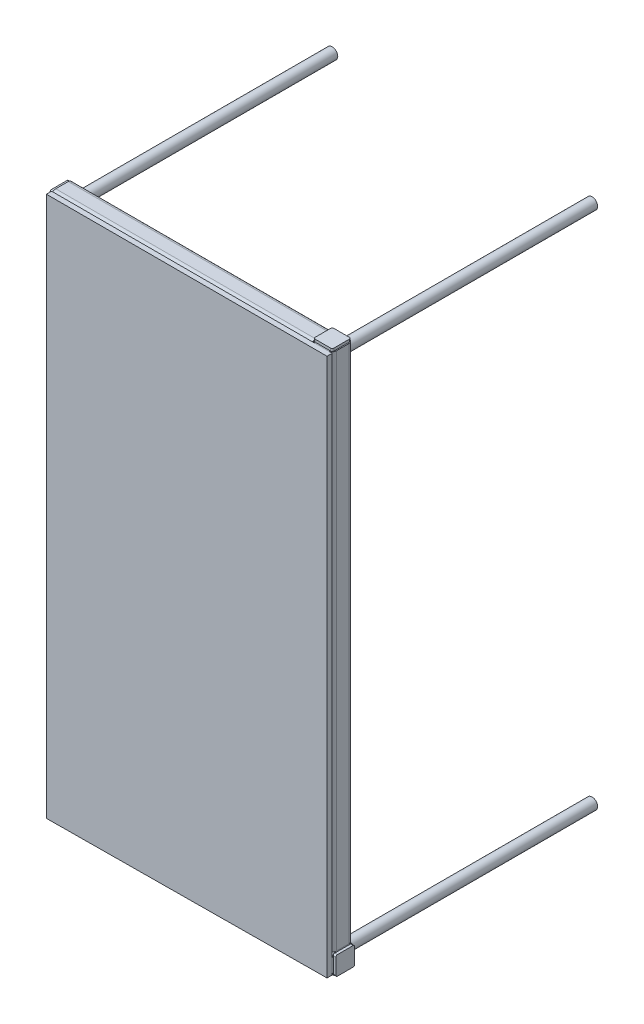
from build123d import *

# Parameters (mm, degrees)
STRUCTURAL_MEMBER1_DEPTH      = 1020
STRUCTURAL_MEMBER1_DEPTH_BACK = 1
STRUCTURAL_MEMBER1_2_DEPTH    = 521
STRUCTURAL_MEMBER1_3_DEPTH    = 1021
STRUCTURAL_MEMBER1_4_DEPTH    = 521
SKETCH11_R                    = 10.65
SKETCH11_R_2                  = 8.35
STRUCTURAL_MEMBER2_DEPTH      = 500
SKETCH11_ON_SEGMENT_2_R       = 10.65
SKETCH11_ON_SEGMENT_2_R_2     = 8.35
STRUCTURAL_MEMBER2_2_DEPTH    = 500
SKETCH11_ON_SEGMENT_3_R       = 10.65
SKETCH11_ON_SEGMENT_3_R_2     = 8.35
STRUCTURAL_MEMBER2_3_DEPTH    = 500
SKETCH11_ON_SEGMENT_4_R       = 10.65
SKETCH11_ON_SEGMENT_4_R_2     = 8.35
STRUCTURAL_MEMBER2_4_DEPTH    = 500
END_CAP1_WIDTH                = 36
END_CAP1_HEIGHT               = 36
END_CAP1_THICKNESS            = 5
END_CAP1_2_SIZE               = 3
GUSSET1_THICKNESS             = 5
BOSS_EXTRUDE1_DEPTH           = 10
END_CAP2_WIDTH                = 36
END_CAP2_HEIGHT               = 36
END_CAP2_THICKNESS            = 5
END_CAP2_2_R                  = 3
END_CAP3_WIDTH                = 36
END_CAP3_HEIGHT               = 36
END_CAP3_THICKNESS            = 5
END_CAP3_2_R                  = 3
END_CAP4_WIDTH                = 36
END_CAP4_HEIGHT               = 36
END_CAP4_THICKNESS            = 5
END_CAP4_2_R                  = 3


with BuildPart() as part:
    # Sketch1 → Structural Member1 (new, two sides)
    with BuildSketch(Plane(origin=(-250, 500, 0), x_dir=(1, 0, 0), z_dir=(0, -1, 0))) as structural_member1_sk:
        with BuildLine():
            Line((-12, -20), (12, -20))
            ThreePointArc((12, -20), (17.656854249, -17.656854249), (20, -12))
            Line((20, -12), (20, 12))
            ThreePointArc((20, 12), (17.656854249, 17.656854249), (12, 20))
            Line((12, 20), (-12, 20))
            ThreePointArc((-12, 20), (-17.656854249, 17.656854249), (-20, 12))
            Line((-20, 12), (-20, -12))
            ThreePointArc((-20, -12), (-17.656854249, -17.656854249), (-12, -20))
        make_face()
        with BuildLine():
            Line((-12, -16), (12, -16))
            ThreePointArc((12, -16), (14.828427125, -14.828427125), (16, -12))
            Line((16, -12), (16, 12))
            ThreePointArc((16, 12), (14.828427125, 14.828427125), (12, 16))
            Line((12, 16), (-12, 16))
            ThreePointArc((-12, 16), (-14.828427125, 14.828427125), (-16, 12))
            Line((-16, 12), (-16, -12))
            ThreePointArc((-16, -12), (-14.828427125, -14.828427125), (-12, -16))
        make_face(mode=Mode.SUBTRACT)
    extrude(amount=STRUCTURAL_MEMBER1_DEPTH)
    extrude(structural_member1_sk.sketch, amount=-STRUCTURAL_MEMBER1_DEPTH_BACK)

    # Structural Member1 end butt 1
    split(bisect_by=Plane(origin=(-250, 480, 0), x_dir=(1, 0, 0), z_dir=(0, -1, 0)), keep=Keep.TOP)


with BuildPart() as body_2:
    # Sketch1 on segment 2 (carried to segment 2) → Structural Member1 2 (new body)
    with BuildSketch(Plane(origin=(-251, -500, 0), x_dir=(0, 1, 0), z_dir=(1, 0, 0))):
        with BuildLine():
            Line((-12, -20), (12, -20))
            ThreePointArc((12, -20), (17.656854249, -17.656854249), (20, -12))
            Line((20, -12), (20, 12))
            ThreePointArc((20, 12), (17.656854249, 17.656854249), (12, 20))
            Line((12, 20), (-12, 20))
            ThreePointArc((-12, 20), (-17.656854249, 17.656854249), (-20, 12))
            Line((-20, 12), (-20, -12))
            ThreePointArc((-20, -12), (-17.656854249, -17.656854249), (-12, -20))
        make_face()
        with BuildLine():
            Line((-12, -16), (12, -16))
            ThreePointArc((12, -16), (14.828427125, -14.828427125), (16, -12))
            Line((16, -12), (16, 12))
            ThreePointArc((16, 12), (14.828427125, 14.828427125), (12, 16))
            Line((12, 16), (-12, 16))
            ThreePointArc((-12, 16), (-14.828427125, 14.828427125), (-16, 12))
            Line((-16, 12), (-16, -12))
            ThreePointArc((-16, -12), (-14.828427125, -14.828427125), (-12, -16))
        make_face(mode=Mode.SUBTRACT)
    extrude(amount=STRUCTURAL_MEMBER1_2_DEPTH)

    # Structural Member1 2 end butt 1
    split(bisect_by=Plane(origin=(-230, -500, 0), x_dir=(0, 1, 0), z_dir=(1, 0, 0)), keep=Keep.TOP)


with BuildPart() as body_3:
    # Sketch1 on segment 3 (carried to segment 3) → Structural Member1 3 (new body)
    with BuildSketch(Plane(origin=(250, -501, 0), x_dir=(-1, 0, 0), z_dir=(0, 1, 0))):
        with BuildLine():
            Line((-12, -20), (12, -20))
            ThreePointArc((12, -20), (17.656854249, -17.656854249), (20, -12))
            Line((20, -12), (20, 12))
            ThreePointArc((20, 12), (17.656854249, 17.656854249), (12, 20))
            Line((12, 20), (-12, 20))
            ThreePointArc((-12, 20), (-17.656854249, 17.656854249), (-20, 12))
            Line((-20, 12), (-20, -12))
            ThreePointArc((-20, -12), (-17.656854249, -17.656854249), (-12, -20))
        make_face()
        with BuildLine():
            Line((-12, -16), (12, -16))
            ThreePointArc((12, -16), (14.828427125, -14.828427125), (16, -12))
            Line((16, -12), (16, 12))
            ThreePointArc((16, 12), (14.828427125, 14.828427125), (12, 16))
            Line((12, 16), (-12, 16))
            ThreePointArc((-12, 16), (-14.828427125, 14.828427125), (-16, 12))
            Line((-16, 12), (-16, -12))
            ThreePointArc((-16, -12), (-14.828427125, -14.828427125), (-12, -16))
        make_face(mode=Mode.SUBTRACT)
    extrude(amount=STRUCTURAL_MEMBER1_3_DEPTH)

    # Structural Member1 3 end butt 1
    split(bisect_by=Plane(origin=(250, -480, 0), x_dir=(-1, 0, 0), z_dir=(0, 1, 0)), keep=Keep.TOP)


with BuildPart() as body_4:
    # Sketch1 on segment 4 (carried to segment 4) → Structural Member1 4 (new body)
    with BuildSketch(Plane(origin=(251, 500, 0), x_dir=(0, -1, 0), z_dir=(-1, 0, 0))):
        with BuildLine():
            Line((-12, -20), (12, -20))
            ThreePointArc((12, -20), (17.656854249, -17.656854249), (20, -12))
            Line((20, -12), (20, 12))
            ThreePointArc((20, 12), (17.656854249, 17.656854249), (12, 20))
            Line((12, 20), (-12, 20))
            ThreePointArc((-12, 20), (-17.656854249, 17.656854249), (-20, 12))
            Line((-20, 12), (-20, -12))
            ThreePointArc((-20, -12), (-17.656854249, -17.656854249), (-12, -20))
        make_face()
        with BuildLine():
            Line((-12, -16), (12, -16))
            ThreePointArc((12, -16), (14.828427125, -14.828427125), (16, -12))
            Line((16, -12), (16, 12))
            ThreePointArc((16, 12), (14.828427125, 14.828427125), (12, 16))
            Line((12, 16), (-12, 16))
            ThreePointArc((-12, 16), (-14.828427125, 14.828427125), (-16, 12))
            Line((-16, 12), (-16, -12))
            ThreePointArc((-16, -12), (-14.828427125, -14.828427125), (-12, -16))
        make_face(mode=Mode.SUBTRACT)
    extrude(amount=STRUCTURAL_MEMBER1_4_DEPTH)

    # Structural Member1 4 end butt 1
    split(bisect_by=Plane(origin=(230, 500, 0), x_dir=(0, -1, 0), z_dir=(-1, 0, 0)), keep=Keep.TOP)


with BuildPart() as body_5:
    # Sketch11 → Structural Member2 (new body)
    with BuildSketch(Plane(origin=(-250, -500, 0), x_dir=(1, 0, 0), z_dir=(0, 0, -1))):
        Circle(SKETCH11_R)
        Circle(SKETCH11_R_2, mode=Mode.SUBTRACT)
    extrude(amount=STRUCTURAL_MEMBER2_DEPTH)

    # Trim/Extend1
    split(bisect_by=Plane(origin=(20, -500, -20), x_dir=(0, 1, 0), z_dir=(0, 0, -1)), keep=Keep.TOP)


with BuildPart() as body_6:
    # Sketch11 on segment 2 (carried to segment 2) → Structural Member2 2 (new body)
    with BuildSketch(Plane(origin=(250, -500, 0), x_dir=(1, 0, 0), z_dir=(0, 0, -1))):
        Circle(SKETCH11_ON_SEGMENT_2_R)
        Circle(SKETCH11_ON_SEGMENT_2_R_2, mode=Mode.SUBTRACT)
    extrude(amount=STRUCTURAL_MEMBER2_2_DEPTH)

    # Trim/Extend1
    split(bisect_by=Plane(origin=(20, -500, -20), x_dir=(0, 1, 0), z_dir=(0, 0, -1)), keep=Keep.TOP)


with BuildPart() as body_7:
    # Sketch11 on segment 3 (carried to segment 3) → Structural Member2 3 (new body)
    with BuildSketch(Plane(origin=(-250, 500, 0), x_dir=(1, 0, 0), z_dir=(0, 0, -1))):
        Circle(SKETCH11_ON_SEGMENT_3_R)
        Circle(SKETCH11_ON_SEGMENT_3_R_2, mode=Mode.SUBTRACT)
    extrude(amount=STRUCTURAL_MEMBER2_3_DEPTH)

    # Trim/Extend1
    split(bisect_by=Plane(origin=(20, -500, -20), x_dir=(0, 1, 0), z_dir=(0, 0, -1)), keep=Keep.TOP)


with BuildPart() as body_8:
    # Sketch11 on segment 4 (carried to segment 4) → Structural Member2 4 (new body)
    with BuildSketch(Plane(origin=(250, 500, 0), x_dir=(1, 0, 0), z_dir=(0, 0, -1))):
        Circle(SKETCH11_ON_SEGMENT_4_R)
        Circle(SKETCH11_ON_SEGMENT_4_R_2, mode=Mode.SUBTRACT)
    extrude(amount=STRUCTURAL_MEMBER2_4_DEPTH)

    # Trim/Extend1
    split(bisect_by=Plane(origin=(20, -500, -20), x_dir=(0, 1, 0), z_dir=(0, 0, -1)), keep=Keep.TOP)


with BuildPart() as body_9:
    # End cap1: an end cap: a rectangular plate 5.0 thick over the member's open end
    with BuildSketch(Plane(origin=(-250, -520, 0), x_dir=(1, 0, 0), z_dir=(0, -1, 0))):
        Rectangle(END_CAP1_WIDTH, END_CAP1_HEIGHT)
    extrude(amount=END_CAP1_THICKNESS)

    # End cap1 2
    end_cap1_2_edges = [body_9.edges().sort_by_distance(p)[0] for p in [
        (-268, -522.5, -18),
        (-268, -522.5, 18),
        (-232, -522.5, -18),
        (-232, -522.5, 18),
    ]]
    chamfer(end_cap1_2_edges, length=END_CAP1_2_SIZE)


with BuildPart() as body_10:
    # Gusset1: a gusset: a plate 5.0 thick in the corner of two members, its outline drawn in place
    gusset1_outline = Wire([Line((-230, -480, -2.5), (-230, -455, -2.5)), Line((-230, -455, -2.5), (-205, -480, -2.5)), Line((-205, -480, -2.5), (-230, -480, -2.5))])
    add(extrude(Face(gusset1_outline), amount=GUSSET1_THICKNESS, dir=(0, 0, 1)))


with BuildPart() as body_11:
    # Sketch13 → Boss-Extrude1 (new body)
    with BuildSketch(Plane.XY.offset(20)):
        Polygon((-270, -520), (270, -516), (270, 520), (-270, 520), align=None)
    extrude(amount=BOSS_EXTRUDE1_DEPTH)


with BuildPart() as body_12:
    # End cap2: an end cap: a rectangular plate 5.0 thick over the member's open end
    with BuildSketch(Plane(origin=(270, -500, 0), x_dir=(0, 1, 0), z_dir=(1, 0, 0))):
        Rectangle(END_CAP2_WIDTH, END_CAP2_HEIGHT)
    extrude(amount=END_CAP2_THICKNESS)

    # End cap2 2
    end_cap2_2_edges = [body_12.edges().sort_by_distance(p)[0] for p in [
        (272.5, -518, -18),
        (272.5, -518, 18),
        (272.5, -482, -18),
        (272.5, -482, 18),
    ]]
    fillet(end_cap2_2_edges, radius=END_CAP2_2_R)


with BuildPart() as body_13:
    # End cap3: an end cap: a rectangular plate 5.0 thick over the member's open end
    with BuildSketch(Plane(origin=(250, 520, 0), x_dir=(-1, 0, 0), z_dir=(0, 1, 0))):
        Rectangle(END_CAP3_WIDTH, END_CAP3_HEIGHT)
    extrude(amount=END_CAP3_THICKNESS)

    # End cap3 2
    end_cap3_2_edges = [body_13.edges().sort_by_distance(p)[0] for p in [
        (268, 522.5, -18),
        (268, 522.5, 18),
        (232, 522.5, -18),
        (232, 522.5, 18),
    ]]
    fillet(end_cap3_2_edges, radius=END_CAP3_2_R)


with BuildPart() as body_14:
    # End cap4: an end cap: a rectangular plate 5.0 thick over the member's open end
    with BuildSketch(Plane(origin=(-270, 500, 0), x_dir=(0, -1, 0), z_dir=(-1, 0, 0))):
        Rectangle(END_CAP4_WIDTH, END_CAP4_HEIGHT)
    extrude(amount=END_CAP4_THICKNESS)

    # End cap4 2
    end_cap4_2_edges = [body_14.edges().sort_by_distance(p)[0] for p in [
        (-272.5, 518, -18),
        (-272.5, 518, 18),
        (-272.5, 482, -18),
        (-272.5, 482, 18),
    ]]
    fillet(end_cap4_2_edges, radius=END_CAP4_2_R)


solid = Compound([part.part, body_2.part, body_3.part, body_4.part, body_5.part, body_6.part, body_7.part, body_8.part, body_9.part, body_10.part, body_11.part, body_12.part, body_13.part, body_14.part])
